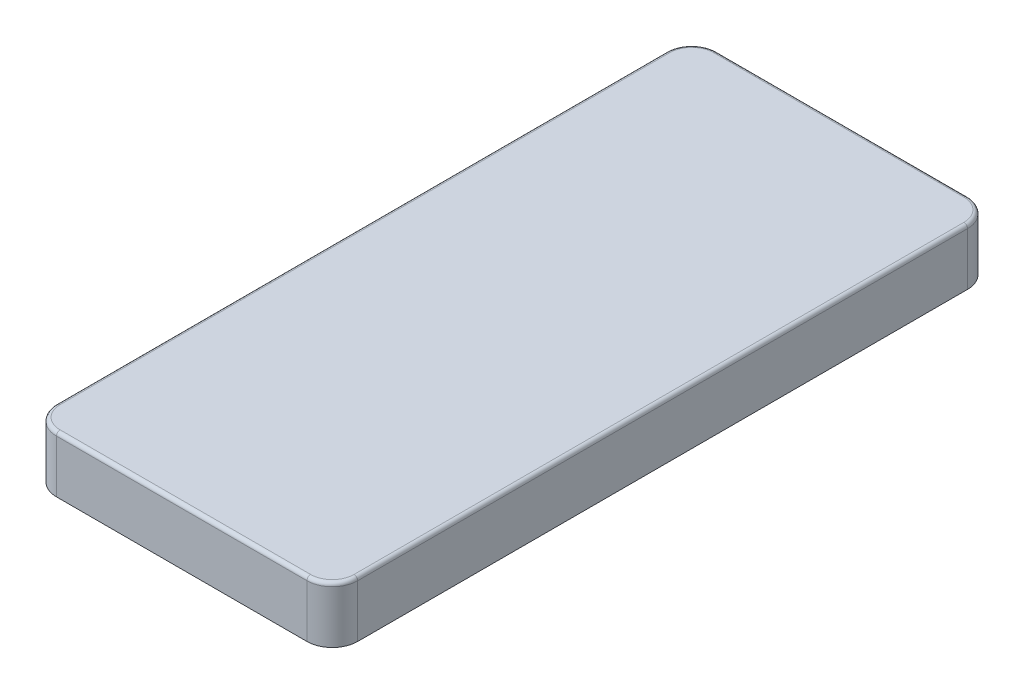
from build123d import *

# Parameters (mm, degrees)
EXTRUDE_1_DEPTH = 15.5
SHELL_1_T       = -2
FILLET_1_R      = 1


with BuildPart() as part:
    # Эскиз2 → Бобышка-Вытянуть1 (new body)
    with BuildSketch(Plane(origin=(0, 0, 0), x_dir=(1, 0, 0), z_dir=(0, 1, 0))):
        with BuildLine():
            Line((-7, 0), (-76, 0))
            ThreePointArc((-76, 0), (-80.949747468, 2.050252532), (-83, 7))
            Line((-83, 7), (-83, 175))
            ThreePointArc((-83, 175), (-80.949747468, 179.949747468), (-76, 182))
            Line((-76, 182), (-7, 182))
            ThreePointArc((-7, 182), (-2.050252532, 179.949747468), (0, 175))
            Line((0, 175), (0, 7))
            ThreePointArc((0, 7), (-2.050252532, 2.050252532), (-7, 0))
        make_face()
    extrude(amount=EXTRUDE_1_DEPTH)

    # Оболочка1
    shell_1_openings = [part.faces().sort_by_distance(p)[0] for p in [
        (-41.5, 0, -91),
    ]]
    offset(amount=SHELL_1_T, openings=shell_1_openings, kind=Kind.INTERSECTION)

    # Скругление1
    fillet_1_edges = [part.edges().sort_by_distance(p)[0] for p in [
        (-2.050252532, 15.5, -179.949747468),
        (-41.5, 15.5, -182),
        (-80.949747468, 15.5, -179.949747468),
        (-83, 15.5, -91),
        (-80.949747468, 15.5, -2.050252532),
        (-41.5, 15.5, 0),
        (-2.050252532, 15.5, -2.050252532),
        (0, 15.5, -91),
    ]]
    fillet(fillet_1_edges, radius=FILLET_1_R)


solid = part.part
